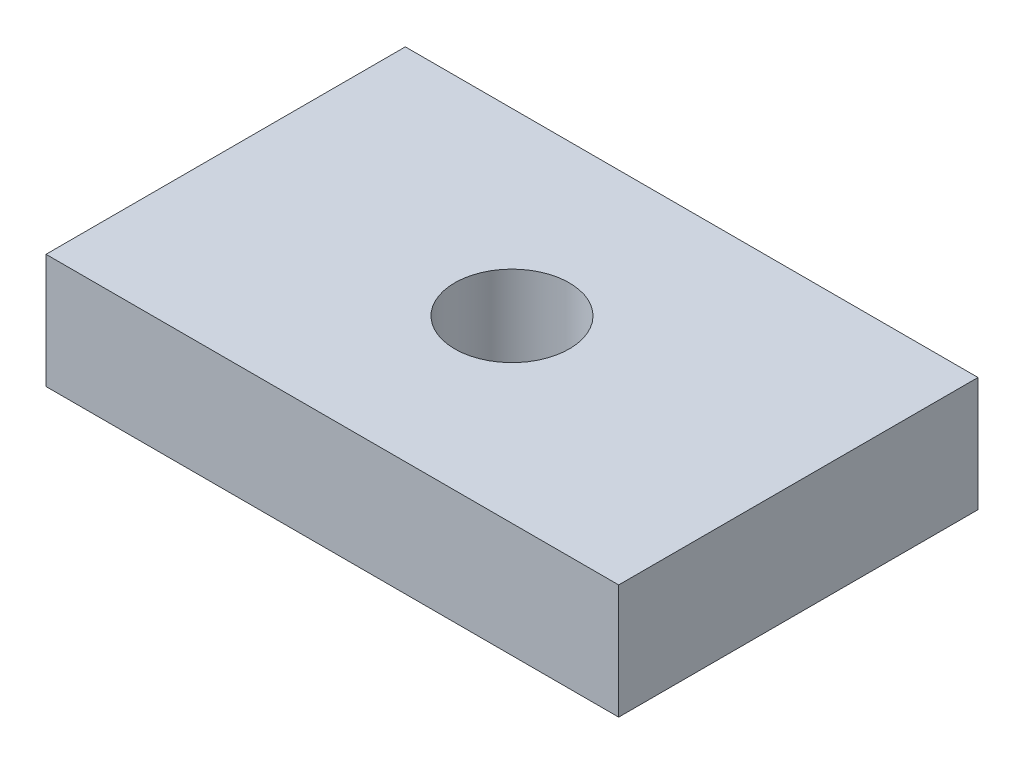
from build123d import *

# Parameters (mm, degrees)
SKETCH1_W           = 50
SKETCH1_H           = 31.372005626
SKETCH1_R           = 5.0025
BOSS_EXTRUDE1_DEPTH = 10


with BuildPart() as part:
    # Sketch1 → Boss-Extrude1 (new body)
    with BuildSketch(Plane(origin=(0, 0, 0), x_dir=(1, 0, 0), z_dir=(0, 1, 0))):
        with Locations((25, 15.686002813)):
            Rectangle(SKETCH1_W, SKETCH1_H)
        with Locations((25, 15.686002813)):
            Circle(SKETCH1_R, mode=Mode.SUBTRACT)
    extrude(amount=BOSS_EXTRUDE1_DEPTH)


solid = part.part
